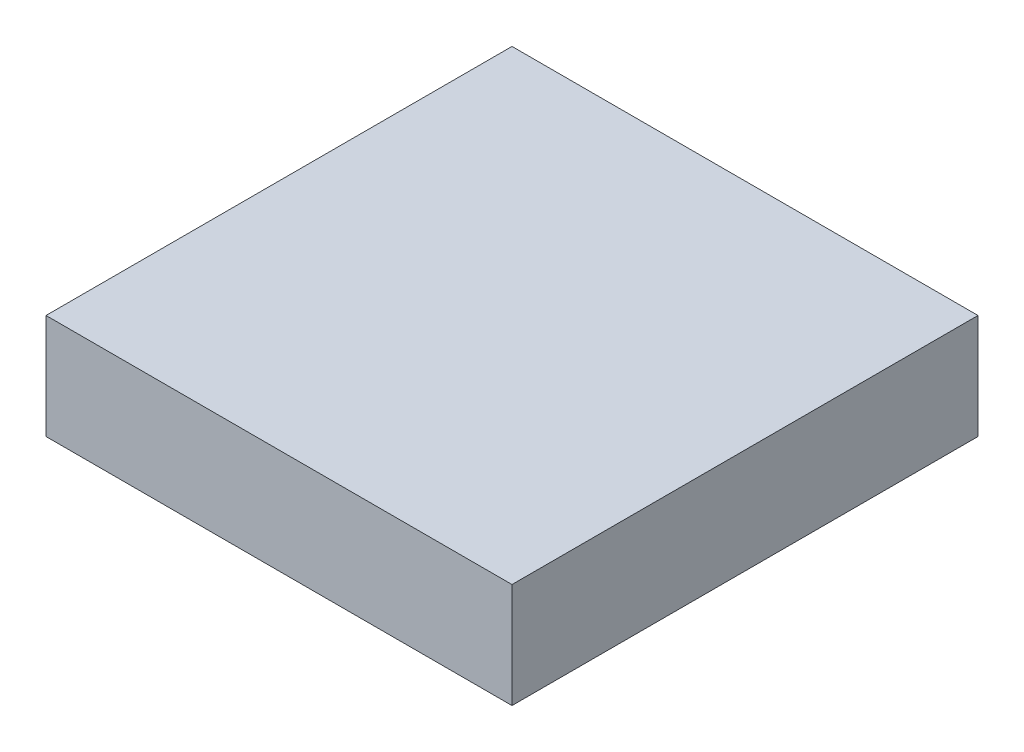
from build123d import *

# Parameters (mm, degrees)
SKETCH1_W           = 4
SKETCH1_H           = 4
BOSS_EXTRUDE1_DEPTH = 0.9


with BuildPart() as part:
    # Sketch1 → Boss-Extrude1 (new body)
    with BuildSketch(Plane(origin=(0, 0, 0), x_dir=(1, 0, 0), z_dir=(0, 1, 0))):
        Rectangle(SKETCH1_W, SKETCH1_H)
    extrude(amount=BOSS_EXTRUDE1_DEPTH)


solid = part.part
